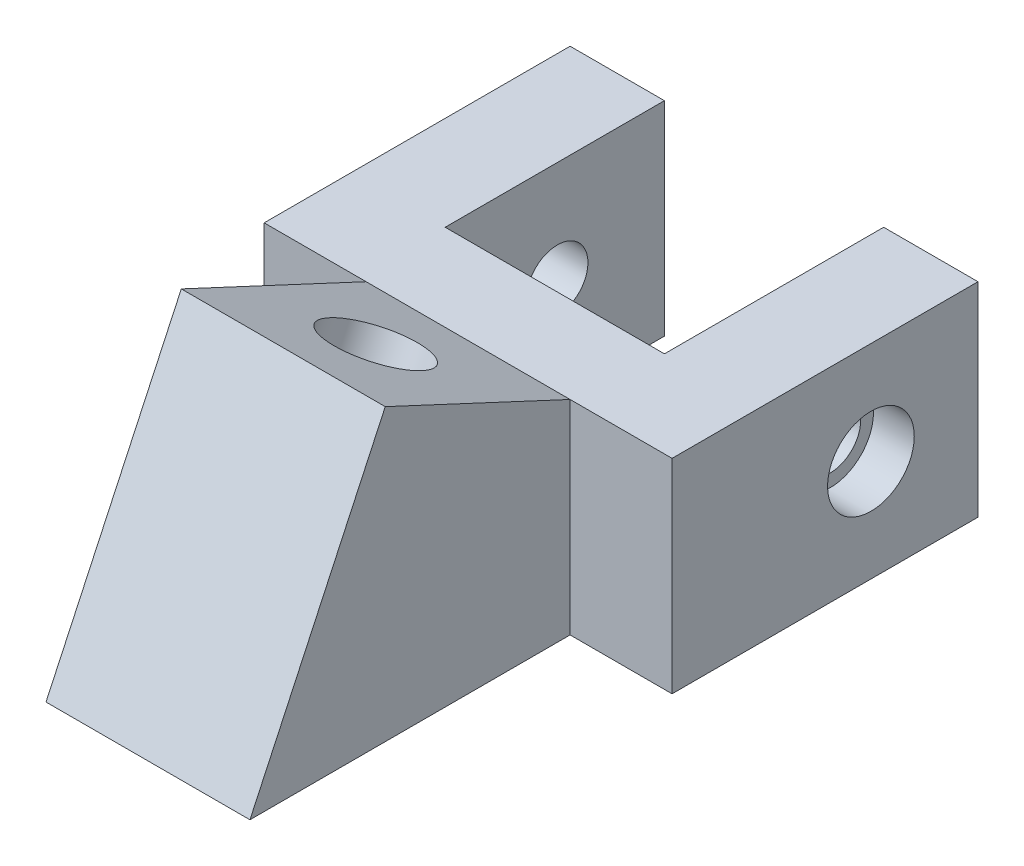
from build123d import *

# Parameters (mm, degrees)
BOSS_EXTRUDE1_DEPTH = 20
BOSS_EXTRUDE3_DEPTH = 10
SKETCH3_R           = 4.5
CUT_EXTRUDE1_DEPTH  = 32.393711542
CUT_EXTRUDE2_DEPTH  = 20
SKETCH5_R           = 3
CUT_EXTRUDE3_DEPTH  = 41
SKETCH6_R           = 4.25
CUT_EXTRUDE4_DEPTH  = 4
SKETCH7_R           = 4.25
CUT_EXTRUDE5_DEPTH  = 4


with BuildPart() as part:
    # Sketch1 → Boss-Extrude1 (new body)
    with BuildSketch(Plane(origin=(0, 0, 0), x_dir=(1, 0, 0), z_dir=(0, 1, 0))):
        Polygon((-10.75, 15), (-10.75, -6.5), (10.75, -6.5), (10.75, 15), (20, 15), (20, -15), (-20, -15), (-20, 15), align=None)
    extrude(amount=BOSS_EXTRUDE1_DEPTH)

    # Sketch2 → Boss-Extrude3 (add, symmetric)
    with BuildSketch(Plane(origin=(0, 0, 0), x_dir=(0, 0, -1), z_dir=(1, 0, 0))):
        Polygon((-15, 20), (-15, 0), (-46.393711542, 0), (-33.126155741, 28.452365235), align=None)
    extrude(amount=BOSS_EXTRUDE3_DEPTH, both=True)

    # Sketch3 → Cut-Extrude1 (cut, through all)
    with BuildSketch(Plane(origin=(0, 10.682542773, -4.981351504), x_dir=(1, 0, 0), z_dir=(0, 0.906307787, -0.422618262))):
        with Locations((0, -32.04698204)):
            Circle(SKETCH3_R)
    extrude(amount=-CUT_EXTRUDE1_DEPTH, mode=Mode.SUBTRACT)

    # Sketch4 → Cut-Extrude2 (cut)
    with BuildSketch(Plane(origin=(0, -10.162536328, 4.738868516), x_dir=(1, 0, 0), z_dir=(0, 0.906307787, -0.422618262))):
        Polygon((4.041451884, -39.04698204), (8.082903769, -32.04698204), (4.041451884, -25.04698204), (-4.041451884, -25.04698204), (-8.082903769, -32.04698204), (-4.041451884, -39.04698204), align=None)
    extrude(amount=-CUT_EXTRUDE2_DEPTH, mode=Mode.SUBTRACT)

    # Sketch5 → Cut-Extrude3 (cut, through all)
    with BuildSketch(Plane(origin=(20, 0, 0), x_dir=(0, 0, -1), z_dir=(1, 0, 0))):
        with Locations((4.5, 10)):
            Circle(SKETCH5_R)
    extrude(amount=-CUT_EXTRUDE3_DEPTH, mode=Mode.SUBTRACT)

    # Sketch6 → Cut-Extrude4 (cut)
    with BuildSketch(Plane(origin=(20, 0, 0), x_dir=(0, 0, -1), z_dir=(1, 0, 0))):
        with Locations((4.5, 10)):
            Circle(SKETCH6_R)
    extrude(amount=-CUT_EXTRUDE4_DEPTH, mode=Mode.SUBTRACT)

    # Sketch7 → Cut-Extrude5 (cut)
    with BuildSketch(Plane.ZY.offset(20)):
        with Locations((-4.5, 10)):
            Circle(SKETCH7_R)
    extrude(amount=-CUT_EXTRUDE5_DEPTH, mode=Mode.SUBTRACT)


solid = part.part
